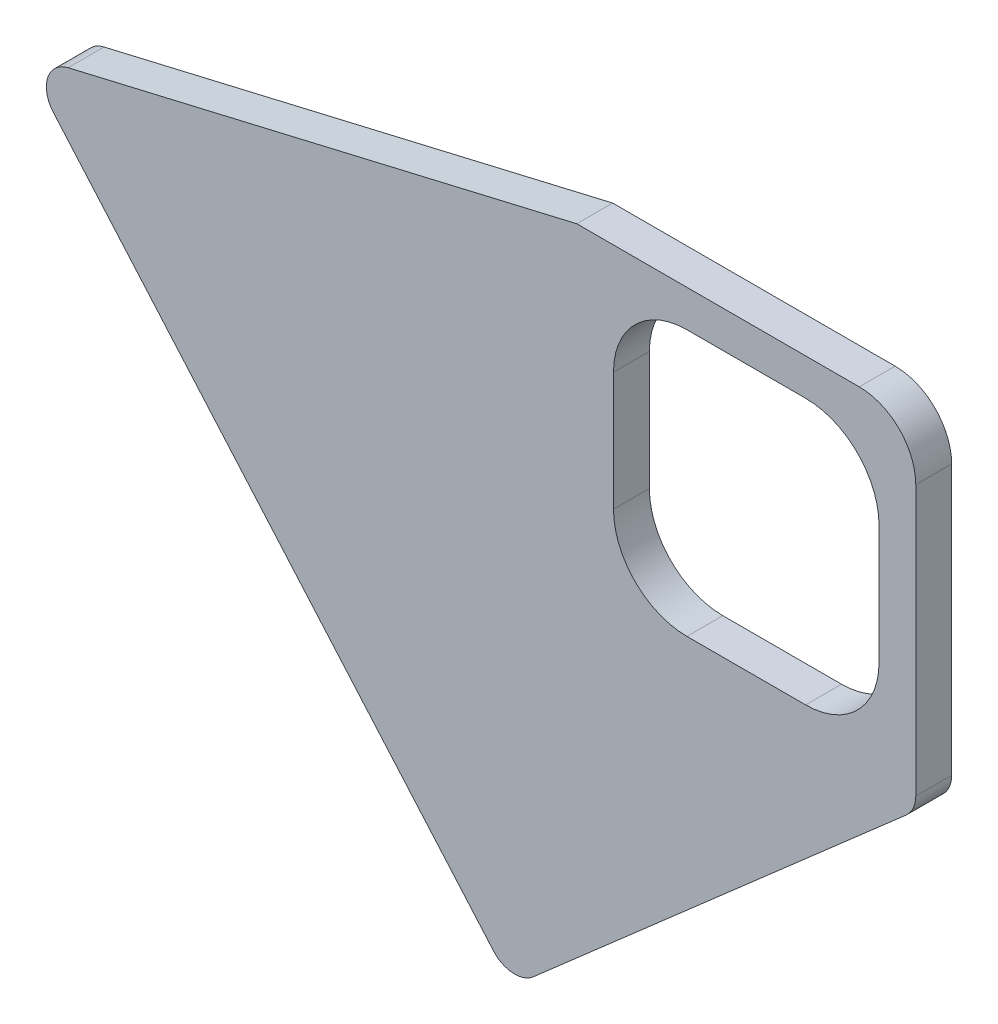
from build123d import *

# Parameters (mm, degrees)
BOSS_EXTRUDE1_DEPTH = 6.35
FILLET1_R           = 10
FILLET2_R           = 5
CUT_EXTRUDE1_DEPTH  = 7.35


with BuildPart() as part:
    # Sketch2 → Boss-Extrude1 (new body)
    with BuildSketch(Plane.XY):
        Polygon((-30, 30), (30, 30), (30, -30), (-41.471442061, -92.584606492), (-128.09675639, 7.014865983), align=None)
    extrude(amount=BOSS_EXTRUDE1_DEPTH)

    # Fillet1
    fillet1_edges = [part.edges().sort_by_distance(p)[0] for p in [
        (30, 30, 3.175),
    ]]
    fillet(fillet1_edges, radius=FILLET1_R)

    # Fillet2
    fillet2_edges = [part.edges().sort_by_distance(p)[0] for p in [
        (-41.471442061, -92.584606492, 3.175),
        (-128.09675639, 7.014865983, 3.175),
        (30, -30, 3.175),
    ]]
    fillet(fillet2_edges, radius=FILLET2_R)

    # Sketch3 → Cut-Extrude1 (cut, through all)
    with BuildSketch(Plane.XY.offset(6.35)):
        with BuildLine():
            Line((-10.5, 23.5), (10.5, 23.5))
            ThreePointArc((10.5, 23.5), (19.692388155, 19.692388155), (23.5, 10.5))
            Line((23.5, 10.5), (23.5, -10.5))
            ThreePointArc((23.5, -10.5), (19.692388155, -19.692388155), (10.5, -23.5))
            Line((10.5, -23.5), (-10.5, -23.5))
            ThreePointArc((-10.5, -23.5), (-19.692388155, -19.692388155), (-23.5, -10.5))
            Line((-23.5, -10.5), (-23.5, 10.5))
            ThreePointArc((-23.5, 10.5), (-19.692388155, 19.692388155), (-10.5, 23.5))
        make_face()
    extrude(amount=-CUT_EXTRUDE1_DEPTH, mode=Mode.SUBTRACT)


solid = part.part
